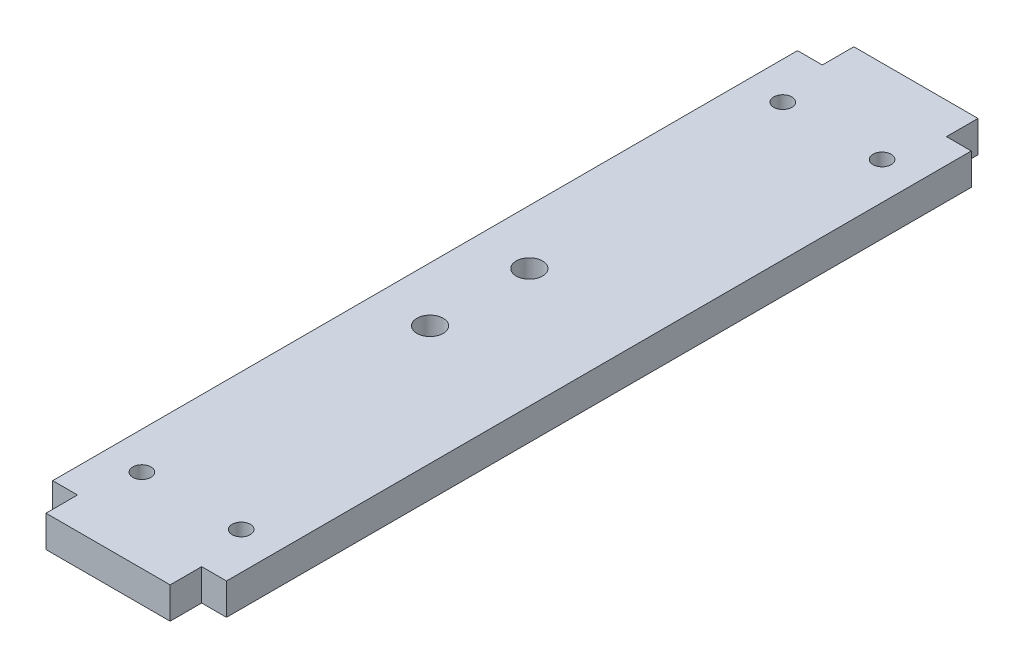
from build123d import *

# Parameters (mm, degrees)
SKETCH1_W             = 35
SKETCH1_H             = 150
BOSS_EXTRUDE1_DEPTH   = 6.35
SKETCH2_W             = 25
SKETCH2_H             = 6.35
BOSS_EXTRUDE2_DEPTH   = 6.35
F_6_CLEARANCE_HOLE1_D = 3.6576
M5_CLEARANCE_HOLE1_D  = 5.3


with BuildPart() as part:
    # Sketch1 → Boss-Extrude1 (new body)
    with BuildSketch(Plane(origin=(0, 0, 0), x_dir=(1, 0, 0), z_dir=(0, 1, 0))):
        Rectangle(SKETCH1_W, SKETCH1_H)
    extrude(amount=BOSS_EXTRUDE1_DEPTH)

    # Sketch2 → Boss-Extrude2 (add)
    with BuildSketch(Plane(origin=(0, 6.35, 0), x_dir=(1, 0, 0), z_dir=(0, 1, 0))):
        with Locations((0, -78.175)):
            Rectangle(SKETCH2_W, SKETCH2_H)
        with Locations((0, 78.175)):
            Rectangle(SKETCH2_W, SKETCH2_H)
    extrude(amount=-BOSS_EXTRUDE2_DEPTH)

    # #6 Clearance Hole1 (through all)
    with Locations(Plane(origin=(-10, 6.35, -64.5352), x_dir=(0, 0, 1), z_dir=(0, 1, 0))):
        with Locations((0, 0), (0, 20), (129.0704, 20), (129.0704, 0)):
            Hole(F_6_CLEARANCE_HOLE1_D / 2)

    # M5 Clearance Hole1 (through all)
    with Locations(Plane(origin=(-6.5, 6.35, 10), x_dir=(0, 0, 1), z_dir=(0, 1, 0))):
        with Locations((0, 0), (-20, 0)):
            Hole(M5_CLEARANCE_HOLE1_D / 2)


solid = part.part
